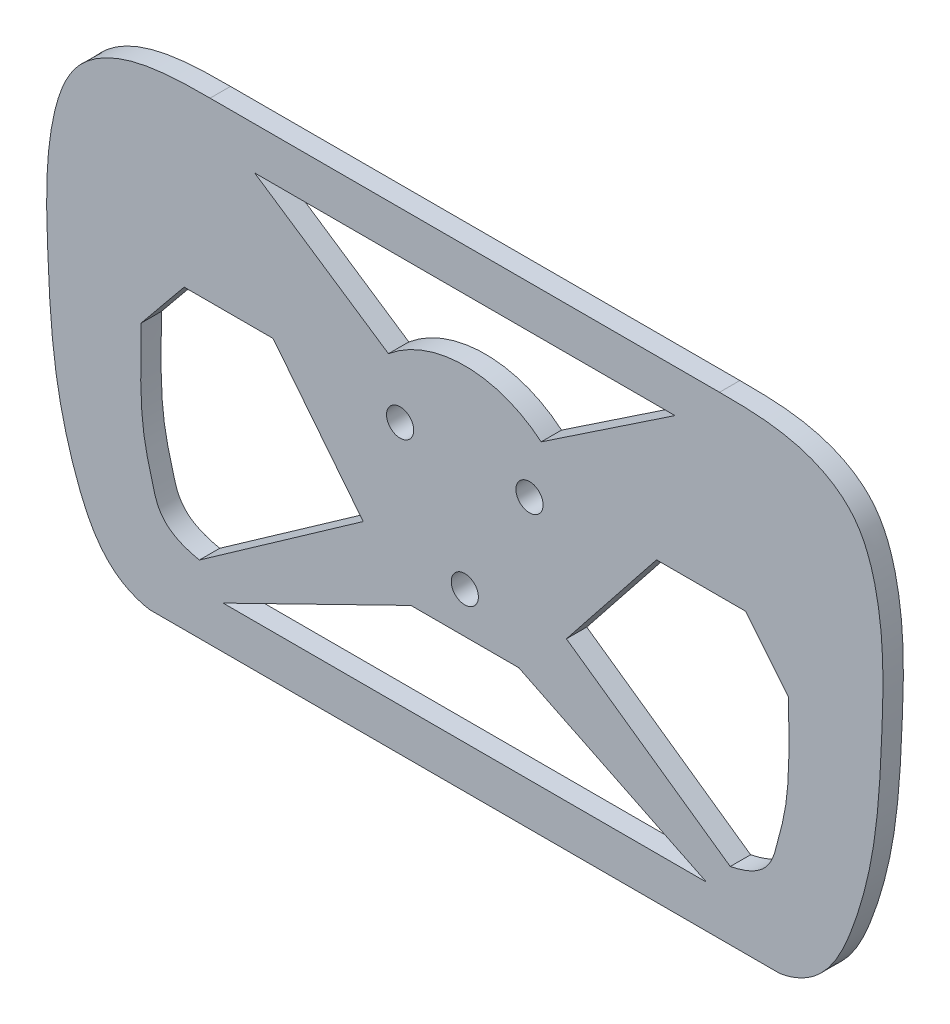
from build123d import *

# Parameters (mm, degrees)
SKETCH1_R           = 4
BOSS_EXTRUDE1_DEPTH = 6


with BuildPart() as part:
    # Sketch1 → Boss-Extrude1 (new body)
    with BuildSketch(Plane.XY):
        with BuildLine():
            Line((-75, 65.725969102), (75, 65.725969102))
            add(Edge.make_bspline(
                [(75, 65.725969102), (83.108190199, 65.725969102), (98.076479253, 65.565413146), (116.227458239, 54.935103324), (123.782270508, 31.987390002), (122.97494253, 4.169272007), (121.472955637, -25.817921846), (114.363626194, -53.881635547), (105.222292521, -71.411509243), (92.841871249, -73.620070941)],
                knots=[0, 0, 0, 0, 0.144554348, 0.228464377, 0.330263898, 0.520750714, 0.69048528, 0.822627379, 1, 1, 1, 1], degree=3))
            Line((92.841871249, -73.620070941), (-92.841871249, -73.620070941))
            add(Edge.make_bspline(
                [(-75, 65.725969102), (-83.108190199, 65.725969102), (-98.076479253, 65.565413146), (-116.227458239, 54.935103324), (-123.782270508, 31.987390002), (-122.97494253, 4.169272007), (-121.472955637, -25.817921846), (-114.363626194, -53.881635547), (-105.222292521, -71.411509243), (-92.841871249, -73.620070941)],
                knots=[0, 0, 0, 0, 0.144554348, 0.228464377, 0.330263898, 0.520750714, 0.69048528, 0.822627379, 1, 1, 1, 1], degree=3))
        make_face()
        with Locations((-19.05, 10.998522628)):
            Circle(SKETCH1_R, mode=Mode.SUBTRACT)
        with Locations((19.05, 10.998522628)):
            Circle(SKETCH1_R, mode=Mode.SUBTRACT)
        with Locations((0, -21.997045256)):
            Circle(SKETCH1_R, mode=Mode.SUBTRACT)
        with BuildLine():
            Line((69.370032777, 29.977750595), (95.356248747, -1.843539004))
            add(Edge.make_bspline(
                [(95.356248747, -1.843539004), (95.557611924, -16.559131142), (95.605964494, -27.343759947), (91.309378512, -43.453128682), (89.212297718, -51.357586705), (78.15487846, -53.630135884)],
                knots=[0, 0, 0, 0, 0.501052944, 0.6781501, 1, 1, 1, 1], degree=3))
            Line((78.15487846, -53.630135884), (29.913407455, -19.693543674))
            Line((29.913407455, -19.693543674), (69.370032777, 29.977750595))
        make_face(mode=Mode.SUBTRACT)
        with BuildLine():
            Line((22.484842809, 26.822226676), (61.892875588, 53.225969102))
            Line((61.892875588, 53.225969102), (-61.892875588, 53.225969102))
            Line((-61.892875588, 53.225969102), (-22.484842809, 26.822226676))
            ThreePointArc((-22.484842809, 26.822226676), (0, 35), (22.484842809, 26.822226676))
        make_face(mode=Mode.SUBTRACT)
        Polygon((-15.875735378, -34.071838731), (-71.170535031, -61.120070941), (71.170535031, -61.120070941), (15.875735378, -34.071838731), align=None, mode=Mode.SUBTRACT)
        with BuildLine():
            add(Edge.make_bspline(
                [(-95.356248747, -1.843539004), (-95.557611924, -16.559131142), (-95.605964494, -27.343759947), (-91.309378512, -43.453128682), (-89.212297718, -51.357586705), (-78.15487846, -53.630135884)],
                knots=[0, 0, 0, 0, 0.501052944, 0.6781501, 1, 1, 1, 1], degree=3))
            Line((-78.15487846, -53.630135884), (-29.913407455, -19.693543674))
            Line((-29.913407455, -19.693543674), (-69.370032777, 29.977750595))
            Line((-69.370032777, 29.977750595), (-95.356248747, -1.843539004))
        make_face(mode=Mode.SUBTRACT)
        Polygon((-56.456677111, 13.721340321), (-69.370032777, 29.977750595), (-82.64550318, 13.721340321), align=None)
        Polygon((82.64550318, 13.721340321), (69.370032777, 29.977750595), (56.456677111, 13.721340321), align=None)
    extrude(amount=BOSS_EXTRUDE1_DEPTH)


solid = part.part
